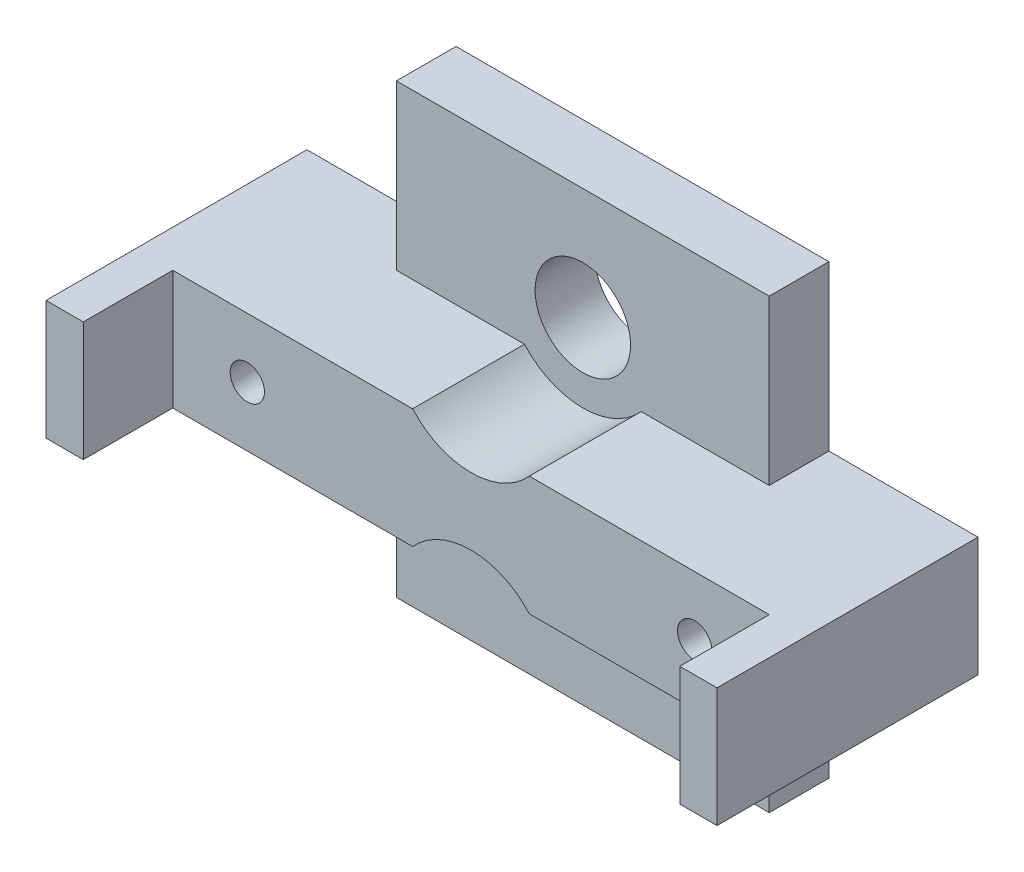
from build123d import *

# Parameters (mm, degrees)
SKETCH_1_W           = 25
SKETCH_1_H           = 30
SKETCH_1_R           = 3.2
EXTRUDE_1_DEPTH      = 4
SKETCH_2_W           = 40
SKETCH_2_H           = 8
SKETCH_2_R           = 1.15
EXTRUDE_2_DEPTH      = 7.5
EXTRUDE_2_DEPTH_BACK = 4
CUT_EXTRUDE_2_DEPTH  = 9.5
SKETCH_5_R           = 5.25
CUT_EXTRUDE_3_DEPTH  = 7.5
SKETCH_6_W           = 2.5
SKETCH_6_H           = 8
EXTRUDE_3_DEPTH      = 17.5


with BuildPart() as part:
    # Sketch 1 → Extrude 1 (new body)
    with BuildSketch(Plane.XY):
        Rectangle(SKETCH_1_W, SKETCH_1_H)
        with Locations((0, 7.5)):
            Circle(SKETCH_1_R, mode=Mode.SUBTRACT)
        with Locations((0, -7.5)):
            Circle(SKETCH_1_R, mode=Mode.SUBTRACT)
    extrude(amount=EXTRUDE_1_DEPTH)

    # Sketch 2 → Extrude 2 (add, two sides)
    with BuildSketch(Plane.XY.offset(4)) as extrude_2_sk:
        Rectangle(SKETCH_2_W, SKETCH_2_H)
        with Locations((15, 0)):
            Circle(SKETCH_2_R, mode=Mode.SUBTRACT)
        with Locations((-15, 0)):
            Circle(SKETCH_2_R, mode=Mode.SUBTRACT)
    extrude(amount=EXTRUDE_2_DEPTH)
    extrude(extrude_2_sk.sketch, amount=-EXTRUDE_2_DEPTH_BACK)

    # Sketch 4 → Cut-Extrude 2 (cut)
    with BuildSketch(Plane(origin=(0, 0, 0), x_dir=(-1, 0, 0), z_dir=(0, 0, -1))):
        Polygon((17.482606158, 0), (16.241303079, 2.15), (13.758696921, 2.15), (12.517393842, 0), (13.758696921, -2.15), (16.241303079, -2.15), align=None)
        Polygon((-12.517393842, 0), (-13.758696921, 2.15), (-16.241303079, 2.15), (-17.482606158, 0), (-16.241303079, -2.15), (-13.758696921, -2.15), align=None)
    extrude(amount=-CUT_EXTRUDE_2_DEPTH, mode=Mode.SUBTRACT)

    # Sketch 5 → Cut-Extrude 3 (cut)
    with BuildSketch(Plane.XY.offset(4)):
        with Locations((0, 7.5)):
            Circle(SKETCH_5_R)
        with Locations((0, -7.5)):
            Circle(SKETCH_5_R)
    extrude(amount=CUT_EXTRUDE_3_DEPTH, mode=Mode.SUBTRACT)

    # Sketch 6 → Extrude 3 (add)
    with BuildSketch(Plane(origin=(0, 0, 0), x_dir=(-1, 0, 0), z_dir=(0, 0, -1))):
        with Locations((21.25, 0)):
            Rectangle(SKETCH_6_W, SKETCH_6_H)
        with Locations((-21.25, 0)):
            Rectangle(SKETCH_6_W, SKETCH_6_H)
    extrude(amount=-EXTRUDE_3_DEPTH)


solid = part.part
